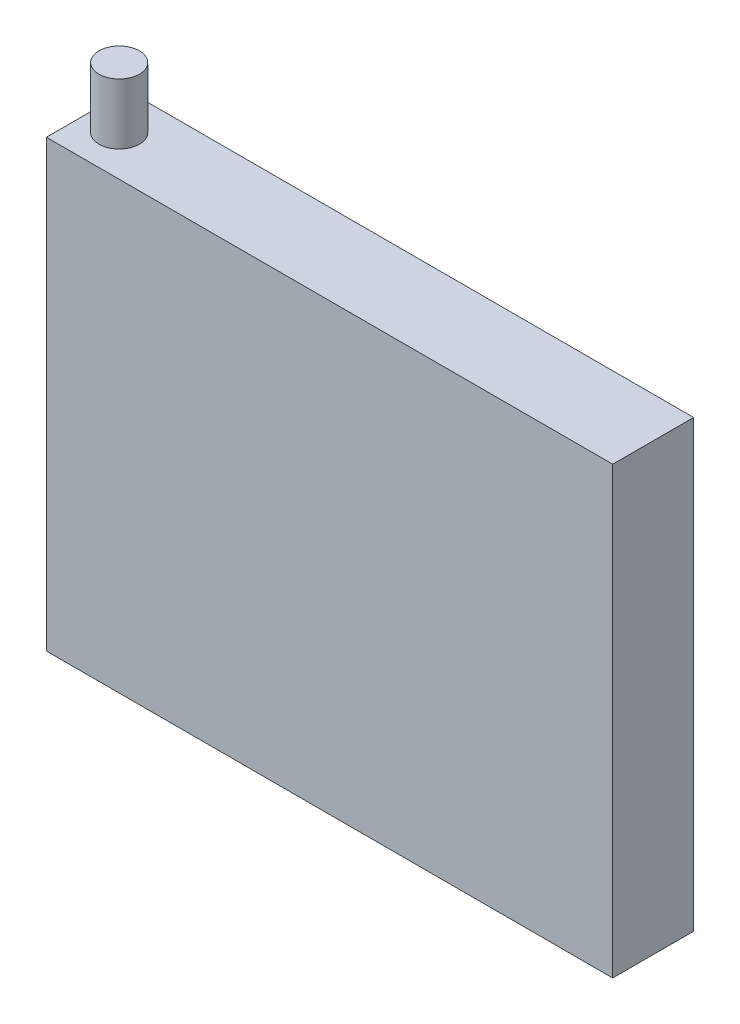
from build123d import *

# Parameters (mm, degrees)
SKETCH1_W           = 70
SKETCH1_H           = 55
BOSS_EXTRUDE1_DEPTH = 10
SKETCH2_R           = 2.5
BOSS_EXTRUDE2_DEPTH = 35
SKETCH3_R           = 2.5
CUT_EXTRUDE1_DEPTH  = 10


with BuildPart() as part:
    # Sketch1 → Boss-Extrude1 (new body)
    with BuildSketch(Plane.XY):
        Rectangle(SKETCH1_W, SKETCH1_H)
    extrude(amount=BOSS_EXTRUDE1_DEPTH)

    # Sketch2 → Boss-Extrude2 (add, symmetric)
    with BuildSketch(Plane(origin=(0, 0, 0), x_dir=(1, 0, 0), z_dir=(0, 1, 0))):
        with Locations((-31, -5)):
            Circle(SKETCH2_R)
    extrude(amount=BOSS_EXTRUDE2_DEPTH, both=True)

    # Sketch3 → Cut-Extrude1 (cut)
    with BuildSketch(Plane.XZ.offset(35)):
        with Locations((-31, 5)):
            Circle(SKETCH3_R)
    extrude(amount=-CUT_EXTRUDE1_DEPTH, mode=Mode.SUBTRACT)


solid = part.part
